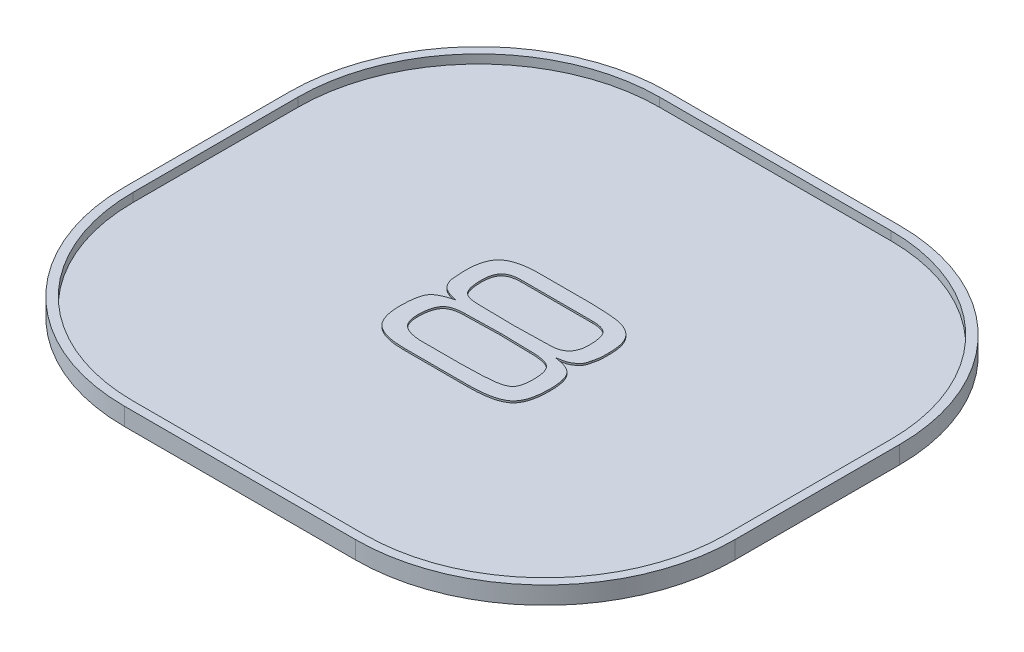
from build123d import *

# Parameters (mm, degrees)
BOSS_EXTRUDE1_DEPTH = 0.2
SHELL1_T            = -0.1
BOSS_EXTRUDE2_DEPTH = 0.02


with BuildPart() as part:
    # Sketch1 → Boss-Extrude1 (new body)
    with BuildSketch(Plane(origin=(0, 0, 0), x_dir=(1, 0, 0), z_dir=(0, 1, 0))):
        with BuildLine():
            Line((-1.353867041, -2.998866411), (1.269572706, -2.998866411))
            ThreePointArc((1.269572706, -2.998866411), (2.789852286, -2.369145991), (3.419572706, -0.848866411))
            Line((3.419572706, -0.848866411), (3.419572706, 1.021109483))
            ThreePointArc((3.419572706, 1.021109483), (2.789852286, 2.541389063), (1.269572706, 3.171109483))
            Line((1.269572706, 3.171109483), (-1.353867041, 3.171109483))
            ThreePointArc((-1.353867041, 3.171109483), (-2.87414662, 2.541389063), (-3.503867041, 1.021109483))
            Line((-3.503867041, 1.021109483), (-3.503867041, -0.848866411))
            ThreePointArc((-3.503867041, -0.848866411), (-2.87414662, -2.369145991), (-1.353867041, -2.998866411))
        make_face()
    extrude(amount=BOSS_EXTRUDE1_DEPTH)

    # Shell1
    shell1_openings = [part.faces().sort_by_distance(p)[0] for p in [
        (-0.042147167, 0.2, -0.086121536),
    ]]
    offset(amount=SHELL1_T, openings=shell1_openings, kind=Kind.INTERSECTION)

    # Sketch2 → Boss-Extrude2 (add)
    with BuildSketch(Plane(origin=(0, 0.1, 0), x_dir=(1, 0, 0), z_dir=(0, 1, 0))):
        with BuildLine():
            Line((0.306291408, -0.762655638), (-0.046247655, -0.762655638))
            Line((-0.046247655, -0.762655638), (-0.418969009, -0.762655638))
            add(Edge.make_bspline(
                [(-0.418969009, -0.762655638), (-0.437423614, -0.762428797), (-0.473074783, -0.761990579), (-0.524582166, -0.757995558), (-0.572187102, -0.751835352), (-0.615718759, -0.742133738), (-0.655660121, -0.730791377), (-0.691473132, -0.716077339), (-0.723601489, -0.699095159), (-0.751962188, -0.679218204), (-0.77670241, -0.655452963), (-0.79808229, -0.627569312), (-0.815430027, -0.594824874), (-0.830266949, -0.558248032), (-0.840992489, -0.517164953), (-0.849164156, -0.472020571), (-0.853997208, -0.422373329), (-0.854552266, -0.38777489), (-0.854841405, -0.369751992)],
                knots=[0, 0, 0, 0, 5.5354e-05, 0.000106934, 0.000154904, 0.000199216, 0.000240622, 0.00027931, 0.000315136, 0.000349458, 0.000382841, 0.000417674, 0.000454382, 0.000493673, 0.000535842, 0.000581495, 0.000631215, 0.000685275, 0.000685275, 0.000685275, 0.000685275], degree=3))
            add(Edge.make_bspline(
                [(-0.854841405, -0.369751992), (-0.854775797, -0.354664153), (-0.85464969, -0.325663157), (-0.852052496, -0.284003072), (-0.849311045, -0.245792973), (-0.843817708, -0.21142698), (-0.837956268, -0.18054781), (-0.830125517, -0.153446377), (-0.821077057, -0.129871215), (-0.810577179, -0.109068766), (-0.796597921, -0.090878043), (-0.779044703, -0.074262236), (-0.757706278, -0.058463356), (-0.732017281, -0.044563218), (-0.702910163, -0.030464823), (-0.669304813, -0.018697867), (-0.632122935, -0.006568741), (-0.60565686, -0.000305184), (-0.591820572, 0.002969362)],
                knots=[0, 0, 0, 0, 4.5252e-05, 8.6981e-05, 0.000125206, 0.000160102, 0.00019132, 0.000219445, 0.000244592, 0.000267015, 0.000289086, 0.000313029, 0.000339332, 0.000368484, 0.000400519, 0.000436257, 0.000475172, 0.000517806, 0.000517806, 0.000517806, 0.000517806], degree=3))
            Line((-0.591820572, 0.002969362), (-0.692406509, 0.029662071))
            add(Edge.make_bspline(
                [(-0.692406509, 0.029662071), (-0.701527046, 0.03309807), (-0.719211497, 0.039760371), (-0.743260536, 0.053723922), (-0.764230693, 0.069996461), (-0.782265771, 0.088888185), (-0.796921427, 0.11069822), (-0.808970047, 0.13515752), (-0.818940132, 0.162162751), (-0.822871976, 0.181502579), (-0.824893488, 0.191445925)],
                knots=[0, 0, 0, 0, 2.9197e-05, 5.6613e-05, 8.305e-05, 0.000108609, 0.000134612, 0.000161544, 0.000190273, 0.000220674, 0.000220674, 0.000220674, 0.000220674], degree=3))
            Line((-0.824893488, 0.191445925), (-0.834008072, 0.342487591))
            add(Edge.make_bspline(
                [(-0.834008072, 0.342487591), (-0.833721165, 0.360945527), (-0.833169879, 0.396412097), (-0.828304912, 0.447232699), (-0.820301592, 0.49355088), (-0.808958729, 0.53516853), (-0.794978586, 0.572530217), (-0.77662071, 0.604616144), (-0.756163826, 0.633142493), (-0.738944971, 0.648013243), (-0.730492447, 0.655313112)],
                knots=[0, 0, 0, 0, 5.5362e-05, 0.000106378, 0.000152992, 0.000196189, 0.000235663, 0.000272244, 0.00030688, 0.000340275, 0.000340275, 0.000340275, 0.000340275], degree=3))
            add(Edge.make_bspline(
                [(-0.730492447, 0.655313112), (-0.721292019, 0.66170897), (-0.702160865, 0.675008368), (-0.669678585, 0.691478107), (-0.632943899, 0.705328821), (-0.592138312, 0.717085179), (-0.547231113, 0.725867351), (-0.498475389, 0.732885053), (-0.445828808, 0.736614325), (-0.409425548, 0.737095943), (-0.390648697, 0.737344362)],
                knots=[0, 0, 0, 0, 3.3585e-05, 6.9837e-05, 0.00010889, 0.000151234, 0.000197071, 0.000246053, 0.000298932, 0.000355262, 0.000355262, 0.000355262, 0.000355262], degree=3))
            Line((-0.390648697, 0.737344362), (-0.008161717, 0.737344362))
            Line((-0.008161717, 0.737344362), (0.20570547, 0.737344362))
            add(Edge.make_bspline(
                [(0.20570547, 0.737344362), (0.225347158, 0.737109909), (0.266381497, 0.736620103), (0.330429028, 0.733992841), (0.399644983, 0.729145799), (0.460021694, 0.724528083), (0.509194535, 0.719075975), (0.544399531, 0.712107831), (0.577537597, 0.703418734), (0.608357288, 0.692409775), (0.636897468, 0.679336233), (0.663203284, 0.664257463), (0.687366786, 0.647112301), (0.709109005, 0.627326157), (0.728567784, 0.604916548), (0.745754016, 0.579380668), (0.759458078, 0.550015039), (0.771447564, 0.517662408), (0.779846321, 0.481637489), (0.786417595, 0.442513605), (0.790311831, 0.399965465), (0.790759459, 0.370490391), (0.790991928, 0.355182904)],
                knots=[0, 0, 0, 0, 5.8927e-05, 0.000123108, 0.000192269, 0.000267069, 0.00030478, 0.000340595, 0.000374627, 0.000407472, 0.000438643, 0.000468682, 0.000498312, 0.000527347, 0.000556653, 0.000587169, 0.000619344, 0.000653636, 0.000690506, 0.000730107, 0.000772605, 0.000818522, 0.000818522, 0.000818522, 0.000818522], degree=3))
            add(Edge.make_bspline(
                [(0.790991928, 0.355182904), (0.790843789, 0.343682978), (0.790572664, 0.322635753), (0.79074575, 0.293957418), (0.789095182, 0.271199499), (0.788125378, 0.252887636), (0.785278709, 0.236575771), (0.782591823, 0.219238222), (0.778114513, 0.199657004), (0.774834213, 0.185800288), (0.773088283, 0.178425091)],
                knots=[0, 0, 0, 0, 3.4507e-05, 6.3154e-05, 8.5978e-05, 0.000102955, 0.000118101, 0.000135601, 0.000155586, 0.000178325, 0.000178325, 0.000178325, 0.000178325], degree=3))
            add(Edge.make_bspline(
                [(0.773088283, 0.178425091), (0.770549171, 0.166052873), (0.765765707, 0.142744698), (0.752970922, 0.111084195), (0.735847428, 0.084790214), (0.720581402, 0.071990237), (0.713192449, 0.065794883)],
                knots=[0, 0, 0, 0, 3.7819e-05, 7.1248e-05, 0.000101946, 0.000130741, 0.000130741, 0.000130741, 0.000130741], degree=3))
            add(Edge.make_bspline(
                [(0.713192449, 0.065794883), (0.700918971, 0.056765637), (0.676146704, 0.038541389), (0.647545164, 0.027230787), (0.633114324, 0.02152405)],
                knots=[0, 0, 0, 0, 4.5503e-05, 9.1842e-05, 9.1842e-05, 9.1842e-05, 9.1842e-05], degree=3))
            Line((0.633114324, 0.02152405), (0.535458074, 0.001667279))
            add(Edge.make_bspline(
                [(0.535458074, 0.001667279), (0.548832535, -0.000118565), (0.574508481, -0.003546981), (0.611116023, -0.01116427), (0.644359694, -0.01989311), (0.673812517, -0.031249982), (0.700137843, -0.043335353), (0.722886463, -0.057700035), (0.741825886, -0.074059764), (0.757829722, -0.092133531), (0.770398095, -0.113013224), (0.78222717, -0.136168596), (0.790754307, -0.163129729), (0.798900157, -0.192791835), (0.804324222, -0.22587281), (0.809210752, -0.261981865), (0.811087425, -0.301483182), (0.811573007, -0.328845066), (0.811825262, -0.343059284)],
                knots=[0, 0, 0, 0, 4.0466e-05, 7.7685e-05, 0.000112116, 0.000143434, 0.000172264, 0.000198903, 0.00022383, 0.000247134, 0.000270977, 0.000296745, 0.000324951, 0.000355586, 0.000388982, 0.000425401, 0.000464855, 0.000507509, 0.000507509, 0.000507509, 0.000507509], degree=3))
            add(Edge.make_bspline(
                [(0.811825262, -0.343059284), (0.811559384, -0.363143449), (0.811049625, -0.401650084), (0.805929907, -0.456852771), (0.79705311, -0.506745305), (0.785816918, -0.551814297), (0.770026797, -0.591393125), (0.751386586, -0.626127678), (0.728490012, -0.655165203), (0.702240792, -0.679808971), (0.670751109, -0.69940757), (0.634898291, -0.716690262), (0.593328535, -0.73091325), (0.5464229, -0.742283884), (0.494176637, -0.751865606), (0.436405278, -0.7580393), (0.373187817, -0.762000131), (0.329193113, -0.762431228), (0.306291408, -0.762655638)],
                knots=[0, 0, 0, 0, 6.0243e-05, 0.000115502, 0.000166077, 0.000212187, 0.000254561, 0.000293609, 0.00033001, 0.000365024, 0.000401052, 0.000440798, 0.000484243, 0.000532561, 0.000585493, 0.000643476, 0.000706748, 0.000775445, 0.000775445, 0.000775445, 0.000775445], degree=3))
        make_face()
        with BuildLine():
            Line((-0.020531509, 0.081094362), (0.383439845, 0.090208946))
            add(Edge.make_bspline(
                [(0.383439845, 0.090208946), (0.400638853, 0.090849108), (0.43322112, 0.092061849), (0.478854715, 0.102291061), (0.517827146, 0.119988504), (0.549813093, 0.145413875), (0.574347099, 0.17835069), (0.591759312, 0.21815786), (0.601558482, 0.264873005), (0.60282271, 0.298169432), (0.603491928, 0.315794883)],
                knots=[0, 0, 0, 0, 5.1557e-05, 9.7671e-05, 0.000139322, 0.000178925, 0.000218899, 0.000261304, 0.000308299, 0.000361155, 0.000361155, 0.000361155, 0.000361155], degree=3))
            add(Edge.make_bspline(
                [(0.603491928, 0.315794883), (0.603377496, 0.326974225), (0.603157329, 0.348483208), (0.601197374, 0.379445253), (0.598028422, 0.407819398), (0.593484319, 0.433702014), (0.587735617, 0.457132607), (0.580626973, 0.478085451), (0.572212548, 0.496486205), (0.562258405, 0.512532677), (0.550356663, 0.52683107), (0.534932653, 0.538457242), (0.516992487, 0.548564153), (0.49593526, 0.556747674), (0.472023659, 0.563084826), (0.445108053, 0.567595726), (0.415279938, 0.570096938), (0.394403814, 0.570477715), (0.383439845, 0.570677696)],
                knots=[0, 0, 0, 0, 3.3535e-05, 6.4521e-05, 9.3028e-05, 0.000119145, 0.000143303, 0.000165333, 0.000185431, 0.000203857, 0.000221864, 0.000240879, 0.00026143, 0.000283494, 0.000308447, 0.000335526, 0.000365262, 0.000398154, 0.000398154, 0.000398154, 0.000398154], degree=3))
            Line((0.383439845, 0.570677696), (-0.015974217, 0.570677696))
            Line((-0.015974217, 0.570677696), (-0.419945572, 0.570677696))
            add(Edge.make_bspline(
                [(-0.419945572, 0.570677696), (-0.429712786, 0.570435624), (-0.448514501, 0.569969641), (-0.475653712, 0.567956074), (-0.500497426, 0.563487535), (-0.523494806, 0.558226876), (-0.544312563, 0.550700311), (-0.563057866, 0.541640961), (-0.579528678, 0.530740891), (-0.594130276, 0.518300172), (-0.606570677, 0.50369661), (-0.617528136, 0.487152857), (-0.626626588, 0.468213392), (-0.633526322, 0.446884895), (-0.639546148, 0.423551543), (-0.643698763, 0.397955498), (-0.645830032, 0.369975977), (-0.646275595, 0.350628944), (-0.646508072, 0.340534466)],
                knots=[0, 0, 0, 0, 2.9313e-05, 5.6427e-05, 8.1526e-05, 0.000104975, 0.000127113, 0.000147785, 0.000167287, 0.000186212, 0.000205137, 0.000224638, 0.000245603, 0.000267941, 0.000291784, 0.000317846, 0.000345609, 0.000375899, 0.000375899, 0.000375899, 0.000375899], degree=3))
            add(Edge.make_bspline(
                [(-0.646508072, 0.340534466), (-0.646400621, 0.329354224), (-0.646194928, 0.307951815), (-0.644158519, 0.277109452), (-0.641170374, 0.248791815), (-0.636095701, 0.223097031), (-0.630489273, 0.199678997), (-0.622982226, 0.179036108), (-0.614538329, 0.160668085), (-0.604385879, 0.144767837), (-0.591914816, 0.130814037), (-0.576343468, 0.11903768), (-0.557579304, 0.109354184), (-0.53584687, 0.101659826), (-0.511209279, 0.095514679), (-0.483562923, 0.091010142), (-0.45276031, 0.08851513), (-0.431234775, 0.088131498), (-0.419945572, 0.0879303)],
                knots=[0, 0, 0, 0, 3.3535e-05, 6.4196e-05, 9.2703e-05, 0.000118879, 0.000142722, 0.00016486, 0.000184663, 0.000203263, 0.000221241, 0.000240512, 0.00026148, 0.000284341, 0.000309526, 0.000337568, 0.000368278, 0.000402146, 0.000402146, 0.000402146, 0.000402146], degree=3))
            Line((-0.419945572, 0.0879303), (-0.020531509, 0.081094362))
        make_face(mode=Mode.SUBTRACT)
        with BuildLine():
            Line((-0.041690363, -0.595988971), (0.012020574, -0.595988971))
            Line((0.012020574, -0.595988971), (0.059221095, -0.595988971))
            add(Edge.make_bspline(
                [(0.059221095, -0.595988971), (0.113588119, -0.595270504), (0.220561095, -0.593856843), (0.339797642, -0.587531638), (0.415637564, -0.579729461), (0.449251757, -0.575013485), (0.479434422, -0.568798087), (0.506310806, -0.561885726), (0.529542468, -0.553296409), (0.549645355, -0.544134014), (0.566098381, -0.533246068), (0.579794292, -0.521303743), (0.590414386, -0.50690818), (0.599549419, -0.490483628), (0.607284485, -0.471438843), (0.613797138, -0.449886028), (0.618629248, -0.425682665), (0.621588169, -0.398883781), (0.62412014, -0.369581549), (0.624255037, -0.349142217), (0.624325262, -0.338501992)],
                knots=[0, 0, 0, 0, 0.000163118, 0.000320953, 0.000357944, 0.000391826, 0.000422725, 0.000450362, 0.000474974, 0.000496961, 0.000516462, 0.00053398, 0.000551168, 0.000569822, 0.000590255, 0.000612704, 0.000637283, 0.000664173, 0.000693559, 0.000725466, 0.000725466, 0.000725466, 0.000725466], degree=3))
            add(Edge.make_bspline(
                [(0.624325262, -0.338501992), (0.624142209, -0.325477546), (0.623792369, -0.30058601), (0.621054335, -0.264977097), (0.615702603, -0.233050357), (0.609227558, -0.204449156), (0.599974643, -0.179487706), (0.589147373, -0.157840762), (0.575986414, -0.139820203), (0.560378018, -0.125362941), (0.542143523, -0.113271409), (0.520533167, -0.103445741), (0.495564223, -0.094944198), (0.467068477, -0.088333497), (0.435132559, -0.082759524), (0.399682042, -0.079017392), (0.36068489, -0.076704721), (0.333530324, -0.076542605), (0.319312241, -0.076457721)],
                knots=[0, 0, 0, 0, 3.9075e-05, 7.4677e-05, 0.000107001, 0.000136134, 0.000162499, 0.000186667, 0.000208542, 0.00022904, 0.000250166, 0.000273902, 0.00030005, 0.000329183, 0.000361561, 0.000397257, 0.000436061, 0.000478709, 0.000478709, 0.000478709, 0.000478709], degree=3))
            Line((0.319312241, -0.076457721), (-0.019229426, -0.069621784))
            Line((-0.019229426, -0.069621784), (-0.414086197, -0.078736367))
            add(Edge.make_bspline(
                [(-0.414086197, -0.078736367), (-0.425921636, -0.078879209), (-0.448665303, -0.079153702), (-0.481200622, -0.082454582), (-0.510794621, -0.087667552), (-0.537547224, -0.094519442), (-0.561268845, -0.104175733), (-0.582216006, -0.115371227), (-0.600231446, -0.128890407), (-0.61510654, -0.144899462), (-0.62759817, -0.16321802), (-0.638402573, -0.183975467), (-0.647429026, -0.207344366), (-0.654468395, -0.233470261), (-0.660350714, -0.262153019), (-0.664539169, -0.293581319), (-0.66665617, -0.327730882), (-0.667106905, -0.351303288), (-0.667341405, -0.363567096)],
                knots=[0, 0, 0, 0, 3.5495e-05, 6.821e-05, 9.7966e-05, 0.000125603, 0.00015087, 0.000174615, 0.000196686, 0.000218103, 0.000239865, 0.000263016, 0.000288163, 0.000314858, 0.000344097, 0.000375954, 0.000409885, 0.000446682, 0.000446682, 0.000446682, 0.000446682], degree=3))
            add(Edge.make_bspline(
                [(-0.667341405, -0.363567096), (-0.667088033, -0.373996165), (-0.666598182, -0.394158971), (-0.662958919, -0.423126961), (-0.657371854, -0.449764053), (-0.648606481, -0.473613953), (-0.638530822, -0.495587867), (-0.624772833, -0.5143776), (-0.609532005, -0.531443951), (-0.591196208, -0.545414383), (-0.570878254, -0.557398949), (-0.548468513, -0.567986539), (-0.523766181, -0.576587485), (-0.496995795, -0.583734215), (-0.468168861, -0.589287132), (-0.437161142, -0.592982122), (-0.403938833, -0.595837396), (-0.380998442, -0.595937389), (-0.369164322, -0.595988971)],
                knots=[0, 0, 0, 0, 3.1277e-05, 6.0469e-05, 8.7479e-05, 0.000112705, 0.000136581, 0.000159702, 0.000182278, 0.000205004, 0.000228507, 0.000252971, 0.000279226, 0.000306862, 0.000336038, 0.000367208, 0.000400513, 0.000436001, 0.000436001, 0.000436001, 0.000436001], degree=3))
            Line((-0.369164322, -0.595988971), (-0.041690363, -0.595988971))
        make_face(mode=Mode.SUBTRACT)
    extrude(amount=BOSS_EXTRUDE2_DEPTH)


solid = part.part
